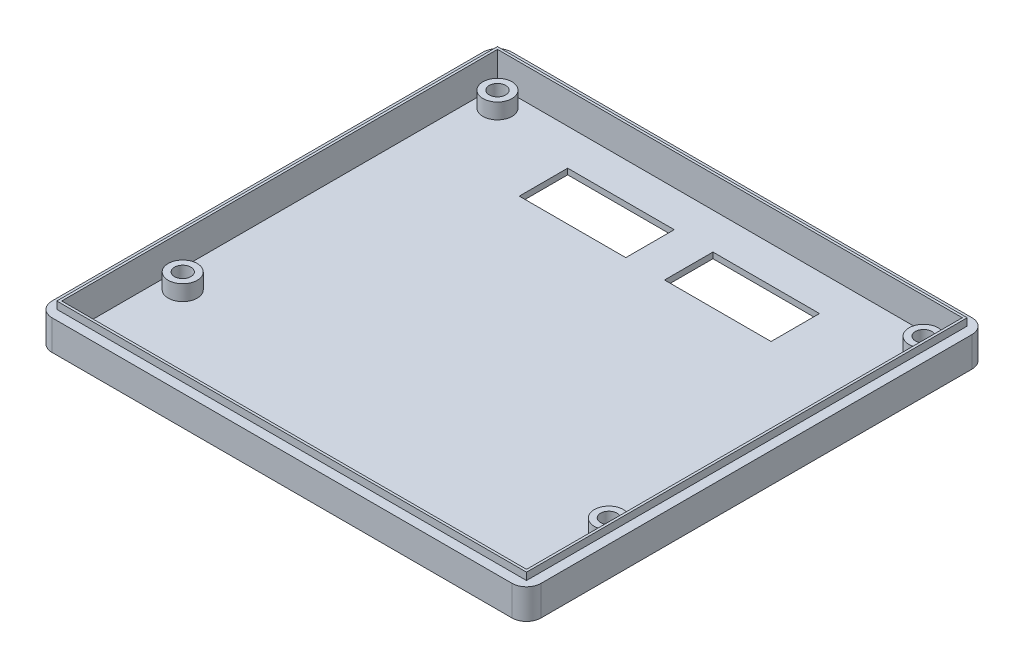
from build123d import *

# Parameters (mm, degrees)
SKETCH1_W           = 101
SKETCH1_H           = 95
BOSS_EXTRUDE1_DEPTH = 1.2
SKETCH3_W           = 101
SKETCH3_H           = 95
SKETCH3_W_2         = 96
SKETCH3_H_2         = 90
BOSS_EXTRUDE2_DEPTH = 5
SKETCH5_R           = 3
BOSS_EXTRUDE3_DEPTH = 3.2
CUT_EXTRUDE1_REACH  = 6.4
SKETCH6_R           = 1.7
CUT_EXTRUDE2_REACH  = 3.2
SKETCH7_W           = 22
SKETCH7_H           = 10
FILLET1_R           = 3
SKETCH8_W           = 97
SKETCH8_H           = 91
SKETCH8_W_2         = 96
SKETCH8_H_2         = 90
BOSS_EXTRUDE4_DEPTH = 1.5


with BuildPart() as part:
    # Sketch1 → Boss-Extrude1 (new body)
    with BuildSketch(Plane(origin=(0, 0, 0), x_dir=(1, 0, 0), z_dir=(0, 1, 0))):
        with Locations((46.5, 43.5)):
            Rectangle(SKETCH1_W, SKETCH1_H)
    extrude(amount=BOSS_EXTRUDE1_DEPTH)

    # Sketch3 → Boss-Extrude2 (add)
    with BuildSketch(Plane(origin=(0, 1.2, 0), x_dir=(1, 0, 0), z_dir=(0, 1, 0))):
        with Locations((46.5, 43.5)):
            Rectangle(SKETCH3_W, SKETCH3_H)
        with Locations((46.5, 43.5)):
            Rectangle(SKETCH3_W_2, SKETCH3_H_2, mode=Mode.SUBTRACT)
    extrude(amount=BOSS_EXTRUDE2_DEPTH)

    # Sketch5 → Boss-Extrude3 (add)
    with BuildSketch(Plane(origin=(0, 1.2, 0), x_dir=(1, 0, 0), z_dir=(0, 1, 0))):
        with Locations((2.5, 84.5)):
            Circle(SKETCH5_R)
        with Locations((90.5, 84.5)):
            Circle(SKETCH5_R)
        with Locations((90.5, 19.5)):
            Circle(SKETCH5_R)
        with Locations((2.5, 19.5)):
            Circle(SKETCH5_R)
    extrude(amount=BOSS_EXTRUDE3_DEPTH)

    # Sketch6 → Cut-Extrude1 (cut, up to next)
    with BuildSketch(Plane(origin=(0, 4.4, 0), x_dir=(1, 0, 0), z_dir=(0, 1, 0)), mode=Mode.PRIVATE) as cut_extrude1_sk1:
        with Locations((2.5, 84.5)):
            Circle(SKETCH6_R)
    cut_extrude1_tool1 = extrude(cut_extrude1_sk1.sketch, amount=-CUT_EXTRUDE1_REACH, mode=Mode.PRIVATE) & part.part
    add(cut_extrude1_tool1.solids().sort_by_distance((2.5, 4.4, -84.5))[0], mode=Mode.SUBTRACT)
    # Sketch6 → Cut-Extrude1 (cut, up to next)
    with BuildSketch(Plane(origin=(0, 4.4, 0), x_dir=(1, 0, 0), z_dir=(0, 1, 0)), mode=Mode.PRIVATE) as cut_extrude1_sk2:
        with Locations((90.5, 84.5)):
            Circle(SKETCH6_R)
    cut_extrude1_tool2 = extrude(cut_extrude1_sk2.sketch, amount=-CUT_EXTRUDE1_REACH, mode=Mode.PRIVATE) & part.part
    add(cut_extrude1_tool2.solids().sort_by_distance((90.5, 4.4, -84.5))[0], mode=Mode.SUBTRACT)
    # Sketch6 → Cut-Extrude1 (cut, up to next)
    with BuildSketch(Plane(origin=(0, 4.4, 0), x_dir=(1, 0, 0), z_dir=(0, 1, 0)), mode=Mode.PRIVATE) as cut_extrude1_sk3:
        with Locations((90.5, 19.5)):
            Circle(SKETCH6_R)
    cut_extrude1_tool3 = extrude(cut_extrude1_sk3.sketch, amount=-CUT_EXTRUDE1_REACH, mode=Mode.PRIVATE) & part.part
    add(cut_extrude1_tool3.solids().sort_by_distance((90.5, 4.4, -19.5))[0], mode=Mode.SUBTRACT)
    # Sketch6 → Cut-Extrude1 (cut, up to next)
    with BuildSketch(Plane(origin=(0, 4.4, 0), x_dir=(1, 0, 0), z_dir=(0, 1, 0)), mode=Mode.PRIVATE) as cut_extrude1_sk4:
        with Locations((2.5, 19.5)):
            Circle(SKETCH6_R)
    cut_extrude1_tool4 = extrude(cut_extrude1_sk4.sketch, amount=-CUT_EXTRUDE1_REACH, mode=Mode.PRIVATE) & part.part
    add(cut_extrude1_tool4.solids().sort_by_distance((2.5, 4.4, -19.5))[0], mode=Mode.SUBTRACT)

    # Sketch7 → Cut-Extrude2 (cut, up to next)
    with BuildSketch(Plane(origin=(0, 1.2, 0), x_dir=(1, 0, 0), z_dir=(0, 1, 0)), mode=Mode.PRIVATE) as cut_extrude2_sk1:
        with Locations((61.5, 76)):
            Rectangle(SKETCH7_W, SKETCH7_H)
    cut_extrude2_tool1 = extrude(cut_extrude2_sk1.sketch, amount=-CUT_EXTRUDE2_REACH, mode=Mode.PRIVATE) & part.part
    add(cut_extrude2_tool1.solids().sort_by_distance((61.5, 1.2, -76))[0], mode=Mode.SUBTRACT)
    # Sketch7 → Cut-Extrude2 (cut, up to next)
    with BuildSketch(Plane(origin=(0, 1.2, 0), x_dir=(1, 0, 0), z_dir=(0, 1, 0)), mode=Mode.PRIVATE) as cut_extrude2_sk2:
        with Locations((31.5, 76)):
            Rectangle(SKETCH7_W, SKETCH7_H)
    cut_extrude2_tool2 = extrude(cut_extrude2_sk2.sketch, amount=-CUT_EXTRUDE2_REACH, mode=Mode.PRIVATE) & part.part
    add(cut_extrude2_tool2.solids().sort_by_distance((31.5, 1.2, -76))[0], mode=Mode.SUBTRACT)

    # Fillet1
    fillet1_edges = [part.edges().sort_by_distance(p)[0] for p in [
        (-4, 3.1, -91),
        (97, 3.1, -91),
        (97, 3.1, 4),
        (-4, 3.1, 4),
    ]]
    fillet(fillet1_edges, radius=FILLET1_R)

    # Sketch8 → Boss-Extrude4 (add)
    with BuildSketch(Plane(origin=(0, 6.2, 0), x_dir=(1, 0, 0), z_dir=(0, 1, 0))):
        with Locations((46.5, 43.5)):
            Rectangle(SKETCH8_W, SKETCH8_H)
        with Locations((46.5, 43.5)):
            Rectangle(SKETCH8_W_2, SKETCH8_H_2, mode=Mode.SUBTRACT)
    extrude(amount=BOSS_EXTRUDE4_DEPTH)


solid = part.part
